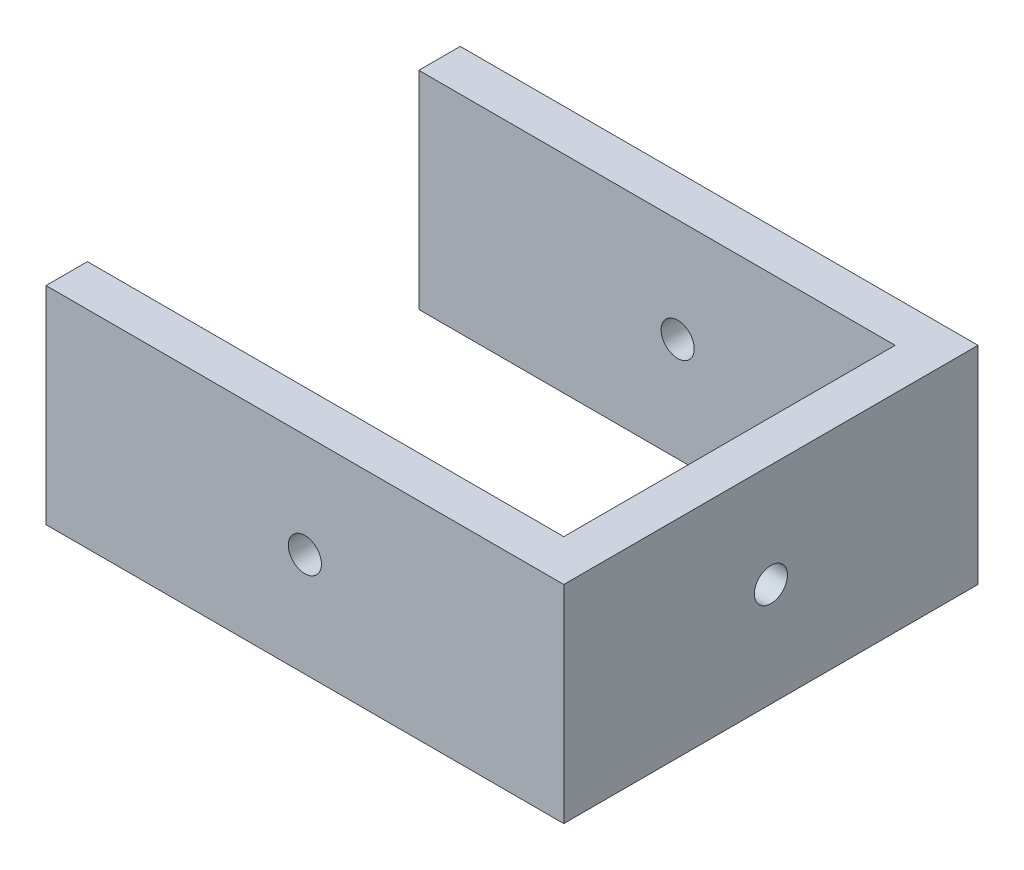
from build123d import *

# Parameters (mm, degrees)
SKETCH5_W           = 100
SKETCH5_H           = 50
SKETCH5_R           = 4
BOSS_EXTRUDE6_DEPTH = 10
SKETCH6_W           = 125
SKETCH6_H           = 50
SKETCH6_R           = 4
BOSS_EXTRUDE7_DEPTH = 10
SKETCH7_W           = 125
SKETCH7_H           = 50
SKETCH7_R           = 4
BOSS_EXTRUDE8_DEPTH = 10


with BuildPart() as part:
    # Sketch5 → Boss-Extrude6 (new body)
    with BuildSketch(Plane(origin=(0, 0, 0), x_dir=(0, 0, -1), z_dir=(1, 0, 0))):
        Rectangle(SKETCH5_W, SKETCH5_H)
        Circle(SKETCH5_R, mode=Mode.SUBTRACT)
    extrude(amount=-BOSS_EXTRUDE6_DEPTH)

    # Sketch6 → Boss-Extrude7 (add)
    with BuildSketch(Plane(origin=(0, 0, -50), x_dir=(-1, 0, 0), z_dir=(0, 0, -1))):
        with Locations((62.5, 0)):
            Rectangle(SKETCH6_W, SKETCH6_H)
        with Locations((62.5, 0)):
            Circle(SKETCH6_R, mode=Mode.SUBTRACT)
    extrude(amount=-BOSS_EXTRUDE7_DEPTH)

    # Sketch7 → Boss-Extrude8 (add)
    with BuildSketch(Plane.XY.offset(50)):
        with Locations((-62.5, 0)):
            Rectangle(SKETCH7_W, SKETCH7_H)
        with Locations((-62.5, 0)):
            Circle(SKETCH7_R, mode=Mode.SUBTRACT)
    extrude(amount=-BOSS_EXTRUDE8_DEPTH)


solid = part.part
